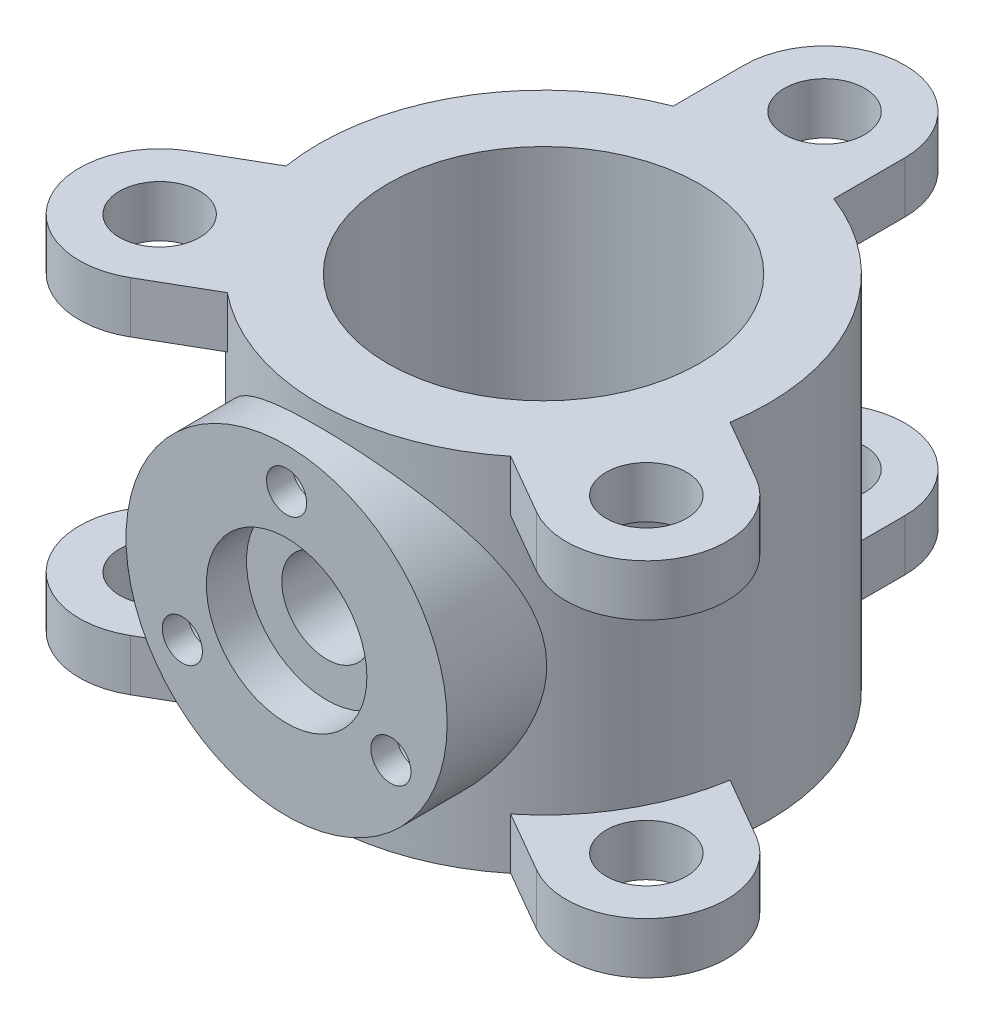
from build123d import *

# Parameters (mm, degrees)
SKETCH1_R                = 140
SKETCH1_R_2              = 97
BOSS_EXTRUDE1_DEPTH      = 112.5
SKETCH2_R                = 25
BOSS_EXTRUDE2_DEPTH      = 32
CIRPATTERN1_COUNT        = 3
MIRROR1_COPY_1_SKETCH_R  = 25
MIRROR1_COPY_1_DEPTH     = 32
MIRROR1_COPY_2_SKETCH_R  = 25
MIRROR1_COPY_2_DEPTH     = 32
BOSS_EXTRUDE3_REACH      = 387
BOSS_EXTRUDE3_END_RADIUS = 140
SKETCH3_R                = 100
CUT_EXTRUDE1_REACH       = 387
CUT_EXTRUDE1_END_RADIUS  = 97
SKETCH4_R                = 28
SKETCH5_R                = 50
CUT_EXTRUDE2_DEPTH       = 25
CIRPATTERN2_COUNT        = 3


with BuildPart() as part:
    # Sketch1 → Boss-Extrude1 (new body, symmetric)
    with BuildSketch(Plane(origin=(0, 0, 0), x_dir=(1, 0, 0), z_dir=(0, 1, 0))):
        with Locations(Location((0, 0, 0), (0, 0, 270))):  # turned: the seam where the file's is
            Circle(SKETCH1_R)
        with Locations(Location((0, 0, 0), (0, 0, 270))):  # turned: the seam where the file's is
            Circle(SKETCH1_R_2, mode=Mode.SUBTRACT)
    extrude(amount=BOSS_EXTRUDE1_DEPTH, both=True)

    # Sketch2 → Boss-Extrude2 (add)
    with BuildSketch(Plane(origin=(0, 112.5, 0), x_dir=(1, 0, 0), z_dir=(0, 1, 0))):
        with BuildLine():
            Line((-50, 175), (-50, 130.766968306))
            ThreePointArc((-50, 130.766968306), (0, 140), (50, 130.766968306))
            Line((50, 130.766968306), (50, 175))
            ThreePointArc((50, 175), (0, 225), (-50, 175))
        make_face()
        with Locations(Location((0, 175, 0), (0, 0, 270))):  # turned: the seam where the file's is
            Circle(SKETCH2_R, mode=Mode.SUBTRACT)
    boss_extrude2 = extrude(amount=-BOSS_EXTRUDE2_DEPTH)

    # CirPattern1: Boss-Extrude2 ×3 about axis
    cirpattern1_axis = Axis((0, 0, 0), (0, 1, 0))
    for i in range(1, CIRPATTERN1_COUNT):
        add(boss_extrude2.rotate(cirpattern1_axis, i * 360 / CIRPATTERN1_COUNT))

    # Mirror1: Boss-Extrude2 across plane
    add(boss_extrude2.mirror(Plane.ZX))

    # Mirror1 copy 1 sketch → Mirror1 copy 1 (add)
    with BuildSketch(Plane(origin=(0, -112.5, 0), x_dir=(-0.5, 0, -0.866025404), z_dir=(0, -1, 0))):
        with BuildLine():
            Line((-50, -175), (-50, -130.766968306))
            ThreePointArc((-50, -130.766968306), (0, -140), (50, -130.766968306))
            Line((50, -130.766968306), (50, -175))
            ThreePointArc((50, -175), (0, -225), (-50, -175))
        make_face()
        with Locations((0, -175)):
            Circle(MIRROR1_COPY_1_SKETCH_R, mode=Mode.SUBTRACT)
    extrude(amount=-MIRROR1_COPY_1_DEPTH)

    # Mirror1 copy 2 sketch → Mirror1 copy 2 (add)
    with BuildSketch(Plane(origin=(0, -112.5, 0), x_dir=(-0.5, 0, 0.866025404), z_dir=(0, -1, 0))):
        with BuildLine():
            Line((-50, -175), (-50, -130.766968306))
            ThreePointArc((-50, -130.766968306), (0, -140), (50, -130.766968306))
            Line((50, -130.766968306), (50, -175))
            ThreePointArc((50, -175), (0, -225), (-50, -175))
        make_face()
        with Locations((0, -175)):
            Circle(MIRROR1_COPY_2_SKETCH_R, mode=Mode.SUBTRACT)
    extrude(amount=-MIRROR1_COPY_2_DEPTH)

    # Boss-Extrude3: up to this cylinder (the profile starts outside it)
    boss_extrude3_end = Plane(origin=(0, 0, 0), z_dir=(0, -1, 0)) * Cylinder(BOSS_EXTRUDE3_END_RADIUS, 1055, mode=Mode.PRIVATE)
    # Sketch3 → Boss-Extrude3 (add, up to the surface)
    with BuildSketch(Plane.XY.offset(160), mode=Mode.PRIVATE) as boss_extrude3_sk1:
        Circle(SKETCH3_R)
    boss_extrude3_tool1 = extrude(boss_extrude3_sk1.sketch, amount=-BOSS_EXTRUDE3_REACH, mode=Mode.PRIVATE) - boss_extrude3_end
    add(boss_extrude3_tool1.solids().sort_by_distance((0, 0, 160))[0])

    # Cut-Extrude1: up to this cylinder (the profile starts outside it)
    cut_extrude1_end = Plane(origin=(0, 0, 0), z_dir=(0, -1, 0)) * Cylinder(CUT_EXTRUDE1_END_RADIUS, 969, mode=Mode.PRIVATE)
    # Sketch4 → Cut-Extrude1 (cut, up to the surface)
    with BuildSketch(Plane.XY.offset(160), mode=Mode.PRIVATE) as cut_extrude1_sk1:
        Circle(SKETCH4_R)
    cut_extrude1_tool1 = extrude(cut_extrude1_sk1.sketch, amount=-CUT_EXTRUDE1_REACH, mode=Mode.PRIVATE) - cut_extrude1_end
    add(cut_extrude1_tool1.solids().sort_by_distance((0, 0, 160))[0], mode=Mode.SUBTRACT)

    # Sketch5 → Cut-Extrude2 (cut)
    with BuildSketch(Plane.XY.offset(160)):
        Circle(SKETCH5_R)
    extrude(amount=-CUT_EXTRUDE2_DEPTH, mode=Mode.SUBTRACT)

    # Sketch7 → Ø25.0mm Dowel Hole1 (revolve, cut)
    with BuildSketch(Plane(origin=(0, 75, 160), x_dir=(0, -1, 0), z_dir=(1, 0, 0))):
        Polygon((0, 0), (0, 23.510757738), (12.5, 16), (12.5, 0), align=None)
    f_25_0mm_dowel_hole1 = revolve(axis=Axis((0, 75, 166.35), (0, 0, -1)), mode=Mode.SUBTRACT)

    # CirPattern2: Ø25.0mm Dowel Hole1 ×3 about axis
    cirpattern2_axis = Axis((0, 0, 0), (0, 0, 1))
    for i in range(1, CIRPATTERN2_COUNT):
        add(f_25_0mm_dowel_hole1.rotate(cirpattern2_axis, i * 360 / CIRPATTERN2_COUNT), mode=Mode.SUBTRACT)


solid = part.part
